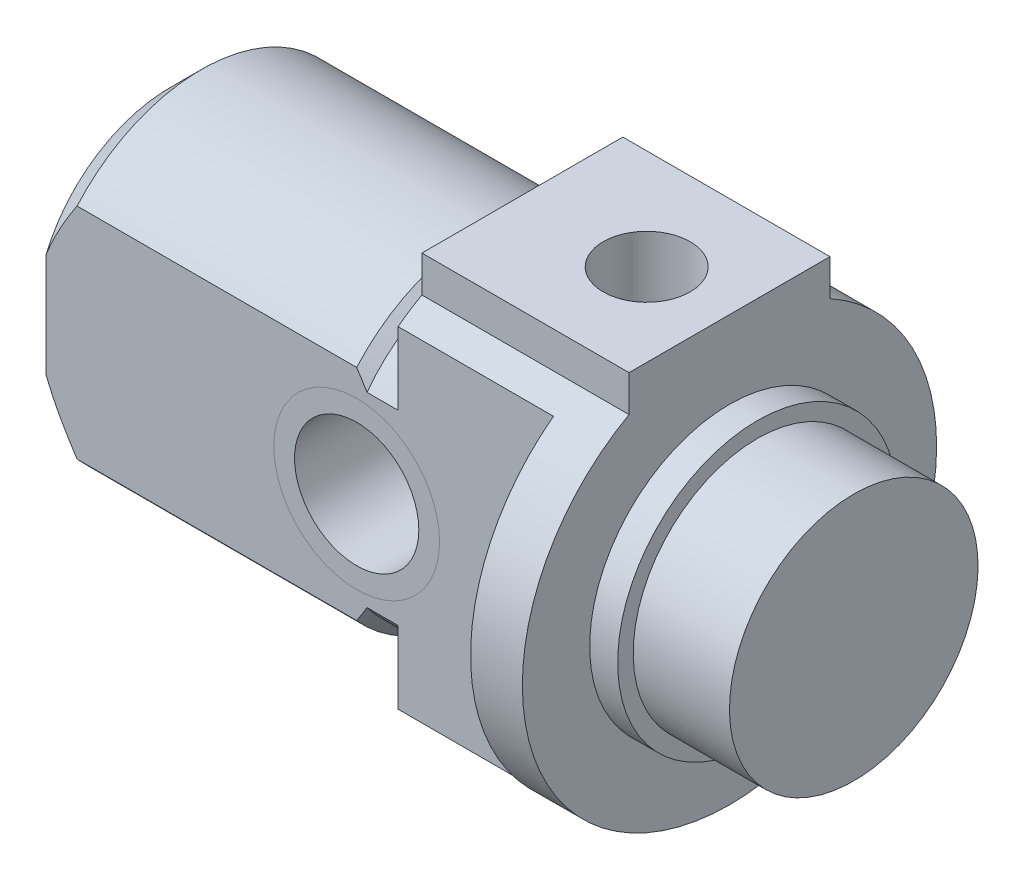
from build123d import *

# Parameters (mm, degrees)
BOSS_EXTRUDE1_DEPTH     = 33
CHAMFER1_SIZE           = 1.5
G1_8_TAPPED_HOLE1_D     = 4.2
G1_8_TAPPED_HOLE1_DEPTH = 11
G1_8_TAPPED_HOLE1_TIP   = 1.2618073
CUT_EXTRUDE2_START      = -3.85
SKETCH7_W               = 15
SKETCH7_H               = 16
CUT_EXTRUDE2_DEPTH      = 25.5
SKETCH8_R               = 4
CUT_EXTRUDE3_DEPTH      = 17
SKETCH11_R              = 4
SKETCH11_R_2            = 3
BOSS_EXTRUDE2_DEPTH     = 12


with BuildPart() as part:
    # Sketch1 → Boss-Extrude1 (new body)
    with BuildSketch(Plane(origin=(0, 0, 0), x_dir=(0, 0, -1), z_dir=(1, 0, 0))):
        with BuildLine():
            Line((-4.85, 8.745141508), (-4.85, 10.5))
            Line((-4.85, 10.5), (4.85, 10.5))
            Line((4.85, 10.5), (4.85, 8.745141508))
            ThreePointArc((4.85, 8.745141508), (0, -10), (-4.85, 8.745141508))
        make_face()
    extrude(amount=BOSS_EXTRUDE1_DEPTH)

    # Sketch2 → Cut-Revolve1 (revolve, cut)
    with BuildSketch(Plane.XY):
        Polygon((27, 14), (27, 6.75), (28.35, 6.75), (28.35, 6), (33, 6), (33, 14), align=None)
    revolve(axis=Axis((45.5, 0, 0), (-1, 0, 0)), mode=Mode.SUBTRACT)

    # Sketch3 → Cut-Revolve2 (revolve, cut)
    with BuildSketch(Plane.XY):
        Polygon((0, 8), (15, 8), (15.5, 7.5), (17, 7.5), (17, 16), (0, 16), align=None)
    revolve(axis=Axis((0, 0, 0), (1, 0, 0)), mode=Mode.SUBTRACT)

    # Chamfer1
    chamfer1_edges = [part.edges().sort_by_distance(p)[0] for p in [
        (0, -8, 0),
    ]]
    chamfer(chamfer1_edges, length=CHAMFER1_SIZE)

    # G1/8 Tapped Hole1
    with Locations(Plane(origin=(0, 10.5, 0), x_dir=(-1, 0, 0), z_dir=(0, 1, 0))):
        with Locations((-23, 0)):
            Hole(G1_8_TAPPED_HOLE1_D / 2, depth=G1_8_TAPPED_HOLE1_DEPTH)
            with Locations((0, 0, -(G1_8_TAPPED_HOLE1_DEPTH + G1_8_TAPPED_HOLE1_TIP / 2))):  # 118° drill point
                Cone(0, G1_8_TAPPED_HOLE1_D / 2, G1_8_TAPPED_HOLE1_TIP, mode=Mode.SUBTRACT)

    # Sketch7 → Cut-Extrude2 (cut, through all)
    with BuildSketch(Plane(origin=(28.35, 0, 0), x_dir=(0, 0, -1), z_dir=(1, 0, 0)).offset(CUT_EXTRUDE2_START)):
        with Locations((-13.5, 0)):
            Rectangle(SKETCH7_W, SKETCH7_H)
    cut_extrude2 = extrude(amount=-CUT_EXTRUDE2_DEPTH, mode=Mode.SUBTRACT)

    # Mirror1: Cut-Extrude2 across plane
    add(cut_extrude2.mirror(Plane.XY), mode=Mode.SUBTRACT)

    # Sketch8 → Cut-Extrude3 (cut, through all)
    with BuildSketch(Plane.XY.offset(6)):
        with Locations((15, 0)):
            Circle(SKETCH8_R)
    extrude(amount=-CUT_EXTRUDE3_DEPTH, mode=Mode.SUBTRACT)


with BuildPart() as body_2:
    # Sketch11 → Boss-Extrude2 (new body)
    with BuildSketch(Plane.XY.offset(6)):
        with Locations((15, 0)):
            Circle(SKETCH11_R)
        with Locations((15, 0)):
            Circle(SKETCH11_R_2, mode=Mode.SUBTRACT)
    extrude(amount=-BOSS_EXTRUDE2_DEPTH)


solid = Compound([part.part, body_2.part])
